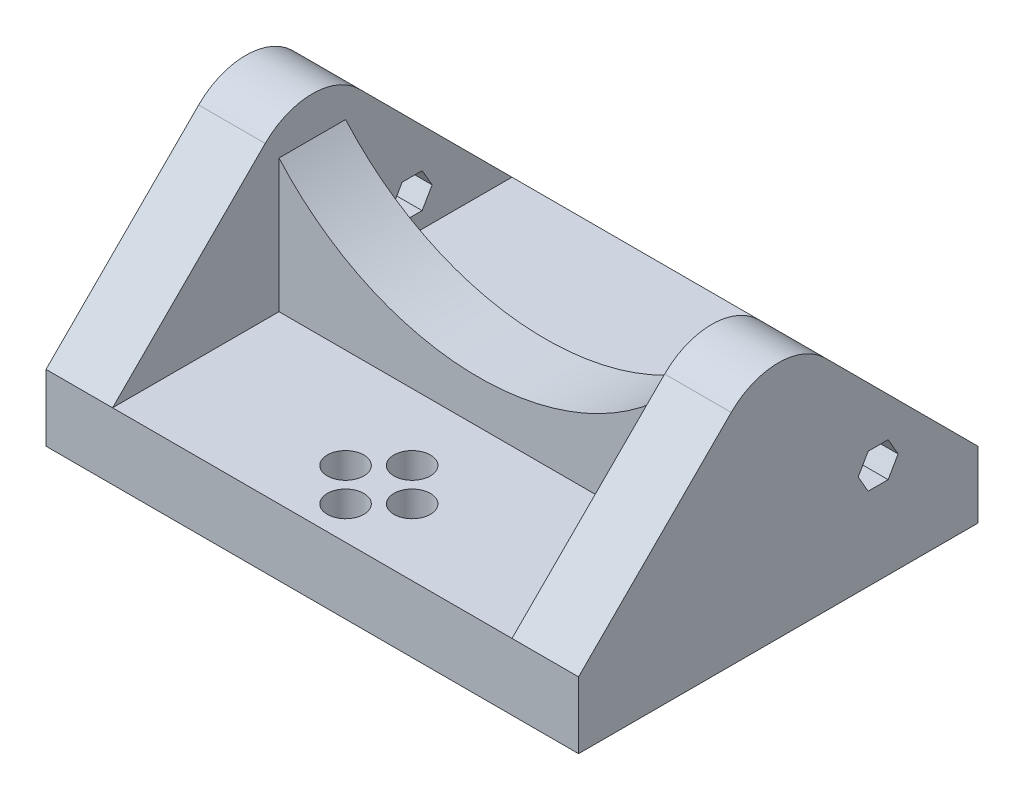
from build123d import *

# Parameters (mm, degrees)
SKETCH1_W           = 80
SKETCH1_H           = 60
BOSS_EXTRUDE1_DEPTH = 10
BOSS_EXTRUDE2_DEPTH = 10
LPATTERN1_COUNT     = 2
LPATTERN1_PITCH     = 70
BOSS_EXTRUDE3_START = -30
BOSS_EXTRUDE3_DEPTH = 5
FILLET1_R           = 10
SKETCH4_R           = 2.739205113
CUT_EXTRUDE1_DEPTH  = 11
CUT_EXTRUDE2_DEPTH  = 81


with BuildPart() as part:
    # Sketch1 → Boss-Extrude1 (new body)
    with BuildSketch(Plane(origin=(0, 0, 0), x_dir=(1, 0, 0), z_dir=(0, 1, 0))):
        with Locations((40, 30)):
            Rectangle(SKETCH1_W, SKETCH1_H)
    extrude(amount=BOSS_EXTRUDE1_DEPTH)

    # Sketch2 → Boss-Extrude2 (add)
    with BuildSketch(Plane(origin=(0, 0, 0), x_dir=(0, 0, -1), z_dir=(1, 0, 0))):
        Polygon((0, 10), (30, 40), (60, 10), align=None)
    boss_extrude2 = extrude(amount=BOSS_EXTRUDE2_DEPTH)

    # LPattern1: Boss-Extrude2 ×2
    with Locations(*[(i * LPATTERN1_PITCH, 0, 0) for i in range(1, LPATTERN1_COUNT)]):
        add(boss_extrude2)

    # Sketch3 → Boss-Extrude3 (add, symmetric)
    with BuildSketch(Plane.XY.offset(BOSS_EXTRUDE3_START)):
        with BuildLine():
            Line((10, 30), (10, 10))
            Line((10, 10), (70, 10))
            Line((70, 10), (70, 30))
            ThreePointArc((70, 30), (40, 16.457513111), (10, 30))
        make_face()
    extrude(amount=BOSS_EXTRUDE3_DEPTH, both=True)

    # Fillet1
    fillet1_edges = [part.edges().sort_by_distance(p)[0] for p in [
        (5, 40, -30),
        (75, 40, -30),
    ]]
    fillet(fillet1_edges, radius=FILLET1_R)

    # Sketch4 → Cut-Extrude1 (cut, through all)
    with BuildSketch(Plane(origin=(0, 10, 0), x_dir=(1, 0, 0), z_dir=(0, 1, 0))):
        with Locations((40, 15)):
            Circle(SKETCH4_R)
        with Locations((45, 10)):
            Circle(SKETCH4_R)
        with Locations((40, 5)):
            Circle(SKETCH4_R)
        with Locations((35, 10)):
            Circle(SKETCH4_R)
    extrude(amount=-CUT_EXTRUDE1_DEPTH, mode=Mode.SUBTRACT)

    # Sketch5 → Cut-Extrude2 (cut, through all)
    with BuildSketch(Plane(origin=(0, 0, 0), x_dir=(0, 0, -1), z_dir=(1, 0, 0))):
        Polygon((46.5, 12.401923789), (48, 15), (46.5, 17.598076211), (43.5, 17.598076211), (42, 15), (43.5, 12.401923789), align=None)
    extrude(amount=CUT_EXTRUDE2_DEPTH, mode=Mode.SUBTRACT)


solid = part.part
